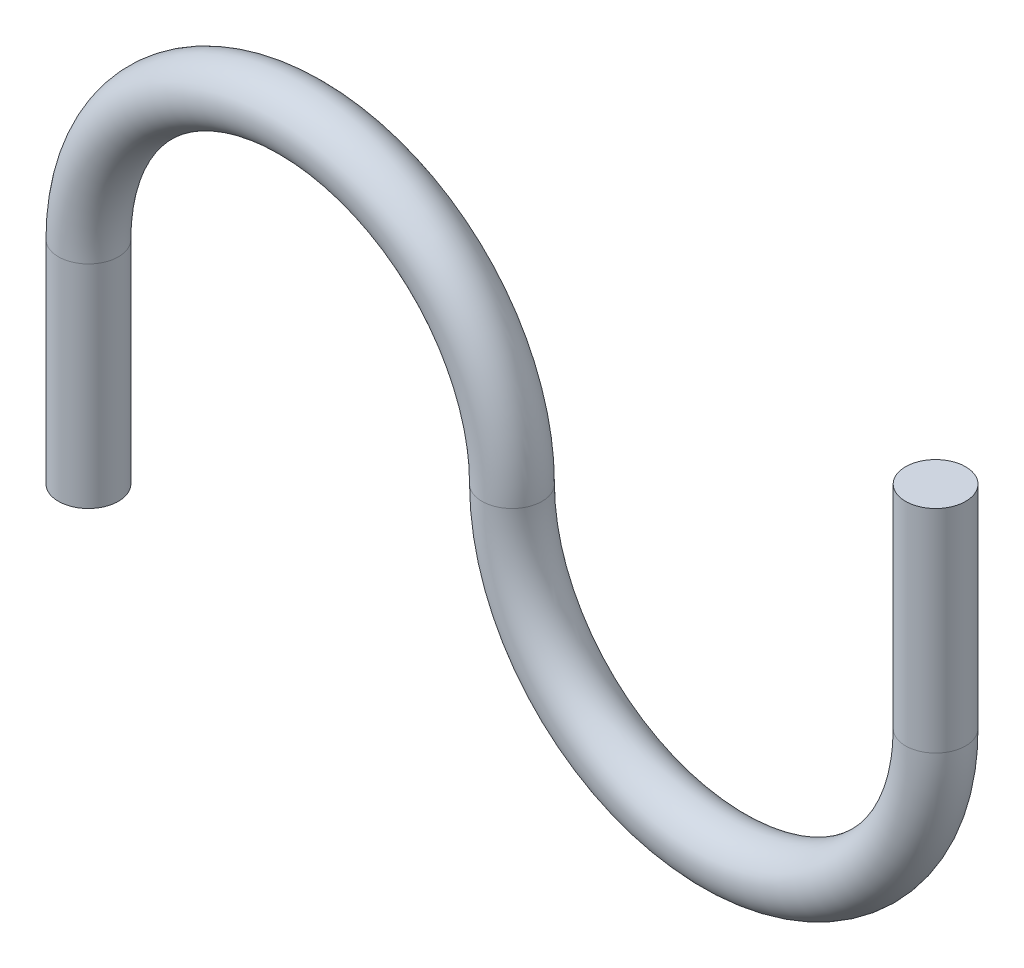
from build123d import *

# Parameters (mm, degrees)
BALAYAGE1_PROFILE_R = 3.175


with BuildPart() as part:
    # Balayage1: sweep along a path in Esquisse1
    with BuildLine(Plane.XY) as balayage1_path:
        Line((-22.4, -22.4), (-22.4, 0))
        ThreePointArc((-22.4, 0), (0, 22.4), (22.4, 0))
        ThreePointArc((22.4, 0), (44.8, -22.4), (67.2, 0))
        Line((67.2, 0), (67.2, 22.4))
    # Balayage1 profile (on start of the path) → Balayage1 (sweep)
    with BuildSketch(Plane(origin=(-22.4, -22.4, 0), x_dir=(0, 0, 1), z_dir=(0, 1, 0))):
        Circle(BALAYAGE1_PROFILE_R)
    sweep(path=balayage1_path.line)


solid = part.part
